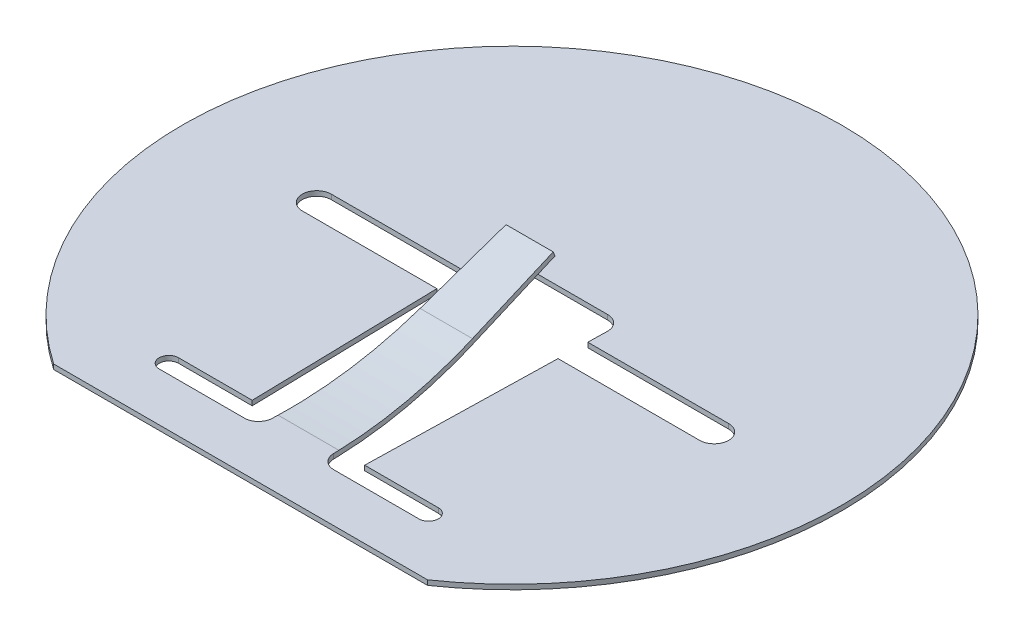
from build123d import *

# Parameters (mm, degrees)
EXTRUDE1_DEPTH = 0.125
SKETCH3_W      = 1.6
SKETCH3_H      = 0.125
EXTRUDE2_DEPTH = 2.616620884
FILLET3_R      = 0.365


with BuildPart() as part:
    # Sketch1 → Extrude1 (new body)
    with BuildSketch(Plane(origin=(0, 0, 0), x_dir=(1, 0, 0), z_dir=(0, 1, 0))):
        with BuildLine():
            Line((4.82182538, -7), (-4.82182538, -7))
            ThreePointArc((-4.82182538, -7), (0, 8.5), (4.82182538, -7))
        make_face()
        with BuildLine():
            Line((1.5625, -0.375), (5.215, -0.375))
            ThreePointArc((5.215, -0.375), (5.59, 0), (5.215, 0.375))
            Line((5.215, 0.375), (1.579807692, 0.375))
            Line((1.579807692, 0.375), (1.591146503, 0.866348457))
            ThreePointArc((1.591146503, 0.866348457), (1.484452699, 1.137088412), (1.216246315, 1.25))
            Line((1.216246315, 1.25), (-1.216246315, 1.25))
            ThreePointArc((-1.216246315, 1.25), (-1.484452699, 1.137088412), (-1.591146503, 0.866348457))
            Line((-1.591146503, 0.866348457), (-1.579807692, 0.375))
            Line((-1.579807692, 0.375), (-5.035, 0.375))
            ThreePointArc((-5.035, 0.375), (-5.41, 0), (-5.035, -0.375))
            Line((-5.035, -0.375), (-1.5625, -0.375))
            Line((-1.5625, -0.375), (-1.45, -5.25))
            Line((-1.45, -5.25), (-3.35, -5.25))
            ThreePointArc((-3.35, -5.25), (-3.6, -5.5), (-3.35, -5.75))
            Line((-3.35, -5.75), (3.35, -5.75))
            ThreePointArc((3.35, -5.75), (3.6, -5.5), (3.35, -5.25))
            Line((3.35, -5.25), (1.45, -5.25))
            Line((1.45, -5.25), (1.5625, -0.375))
        make_face(mode=Mode.SUBTRACT)
    extrude(amount=EXTRUDE1_DEPTH)

    # Sweep2: sweep along a path in Sketch2
    with BuildLine(Plane(origin=(0, 0, 0), x_dir=(0, 0, -1), z_dir=(1, 0, 0))) as sweep2_path:
        Line((0.5, 1.5), (-1.650382858, 0.670329243))
        ThreePointArc((-1.650382858, 0.670329243), (-3.419249821, 0.169010539), (-5.25, 0))
        Line((-5.25, 0), (-5.75, 0))
    # Sketch3 → Sweep2 (sweep)
    with BuildSketch(Plane(origin=(0, 0, 5.75), x_dir=(-1, 0, 0), z_dir=(0, 0, -1))):
        with Locations((0, 0.0625)):
            Rectangle(SKETCH3_W, SKETCH3_H)
    sweep(path=sweep2_path.line)

    # Sketch5 → Extrude2 (cut, through all)
    with BuildSketch(Plane(origin=(0, 0, 0), x_dir=(1, 0, 0), z_dir=(0, 1, 0))):
        Polygon((-0.6, 0.75), (-0.8, -5.75), (-1.2, -5.75), (-1.2, 1), (1.2, 1), (1.2, -5.75), (0.8, -5.75), (0.6, 0.75), align=None)
    extrude(amount=EXTRUDE2_DEPTH, mode=Mode.SUBTRACT)

    # Fillet3
    fillet3_edges = [part.edges().sort_by_distance(p)[0] for p in [
        (0.8, 0.0625, 5.75),
        (-0.8, 0.0625, 5.75),
    ]]
    fillet(fillet3_edges, radius=FILLET3_R)


solid = part.part
